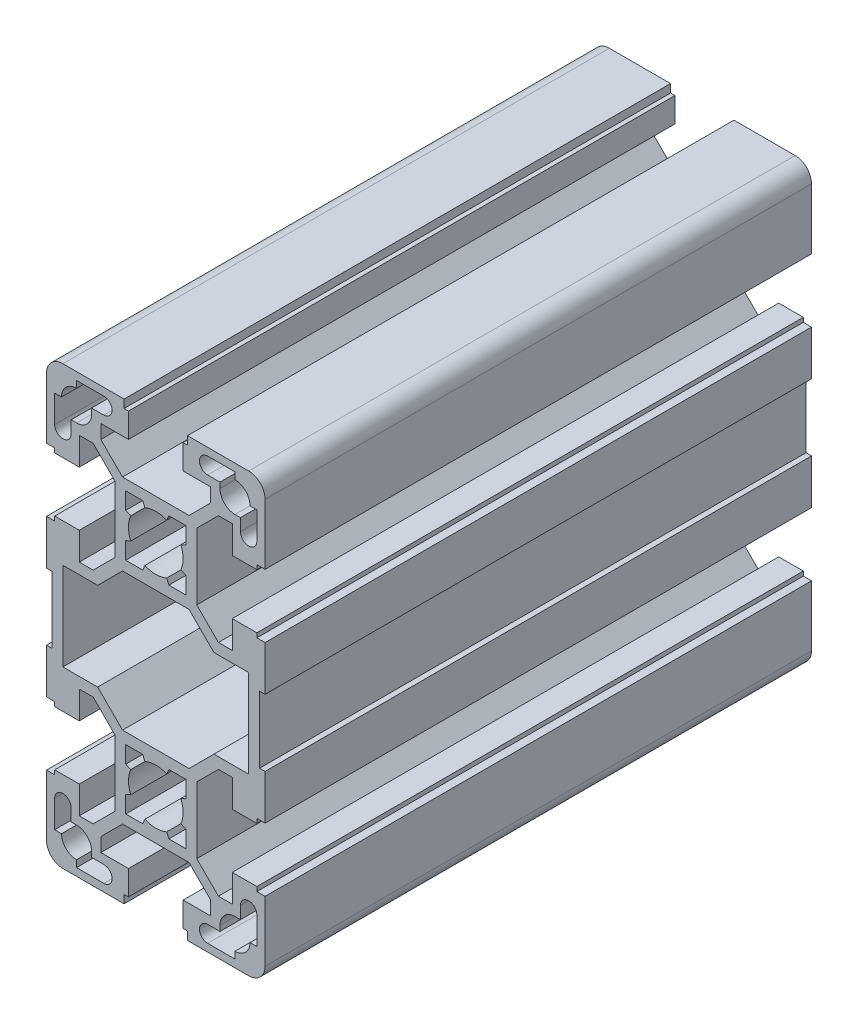
from build123d import *

# Parameters (mm, degrees)
EXTRUDE1_DEPTH = 100


with BuildPart() as part:
    # Sketch1 → Extrude1 (new body)
    with BuildSketch(Plane.XY):
        with BuildLine():
            Line((19, -6.108412677), (20, -6.108412677))
            Line((20, -6.108412677), (20, -14.308412677))
            Line((20, -14.308412677), (18.5, -14.308412677))
            Line((18.5, -14.308412677), (18.5, -15.108412677))
            Line((18.5, -15.108412677), (14, -15.108412677))
            Line((14, -15.108412677), (14, -10.058412677))
            Line((14, -10.058412677), (11.464213562, -10.058412677))
            Line((11.464213562, -10.058412677), (7.5, -14.02262624))
            Line((7.5, -14.02262624), (7.5, -26.194199115))
            Line((7.5, -26.194199115), (11.464213562, -30.158412677))
            Line((11.464213562, -30.158412677), (14, -30.158412677))
            Line((14, -30.158412677), (14, -25.108412677))
            Line((14, -25.108412677), (18.5, -25.108412677))
            Line((18.5, -25.108412677), (18.5, -25.908412677))
            Line((18.5, -25.908412677), (20, -25.908412677))
            Line((20, -25.908412677), (20, -37))
            ThreePointArc((20, -37), (19.121320344, -39.121320344), (17, -40))
            Line((17, -40), (5.8, -40))
            Line((5.8, -40), (5.8, -38.5))
            Line((5.8, -38.5), (5, -38.5))
            Line((5, -38.5), (5, -34))
            Line((5, -34), (10.05, -34))
            Line((10.05, -34), (10.05, -31.464213562))
            Line((10.05, -31.464213562), (6.085786438, -27.5))
            Line((6.085786438, -27.5), (-6.085786438, -27.5))
            Line((-6.085786438, -27.5), (-10.05, -31.464213562))
            Line((-10.05, -31.464213562), (-10.05, -34))
            Line((-10.05, -34), (-5, -34))
            Line((-5, -34), (-5, -38.5))
            Line((-5, -38.5), (-5.8, -38.5))
            Line((-5.8, -38.5), (-5.8, -40))
            Line((-5.8, -40), (-17, -40))
            ThreePointArc((-17, -40), (-19.121320344, -39.121320344), (-20, -37))
            Line((-20, -37), (-20, -25.908412677))
            Line((-20, -25.908412677), (-18.5, -25.908412677))
            Line((-18.5, -25.908412677), (-18.5, -25.108412677))
            Line((-18.5, -25.108412677), (-14, -25.108412677))
            Line((-14, -25.108412677), (-14, -30.158412677))
            Line((-14, -30.158412677), (-11.464213562, -30.158412677))
            Line((-11.464213562, -30.158412677), (-7.5, -26.194199115))
            Line((-7.5, -26.194199115), (-7.5, -14.02262624))
            Line((-7.5, -14.02262624), (-11.464213562, -10.058412677))
            Line((-11.464213562, -10.058412677), (-14, -10.058412677))
            Line((-14, -10.058412677), (-14, -15.108412677))
            Line((-14, -15.108412677), (-18.5, -15.108412677))
            Line((-18.5, -15.108412677), (-18.5, -14.308412677))
            Line((-18.5, -14.308412677), (-20, -14.308412677))
            Line((-20, -14.308412677), (-20, -6.108412677))
            Line((-20, -6.108412677), (-19, -6.108412677))
            Line((-19, -6.108412677), (-19, 6.108412677))
            Line((-19, 6.108412677), (-20, 6.108412677))
            Line((-20, 6.108412677), (-20, 14.308412677))
            Line((-20, 14.308412677), (-18.5, 14.308412677))
            Line((-18.5, 14.308412677), (-18.5, 15.108412677))
            Line((-18.5, 15.108412677), (-14, 15.108412677))
            Line((-14, 15.108412677), (-14, 10.058412677))
            Line((-14, 10.058412677), (-11.464213562, 10.058412677))
            Line((-11.464213562, 10.058412677), (-7.5, 14.02262624))
            Line((-7.5, 14.02262624), (-7.5, 26.194199115))
            Line((-7.5, 26.194199115), (-11.464213562, 30.158412677))
            Line((-11.464213562, 30.158412677), (-14, 30.158412677))
            Line((-14, 30.158412677), (-14, 25.108412677))
            Line((-14, 25.108412677), (-18.5, 25.108412677))
            Line((-18.5, 25.108412677), (-18.5, 25.908412677))
            Line((-18.5, 25.908412677), (-20, 25.908412677))
            Line((-20, 25.908412677), (-20, 37))
            ThreePointArc((-20, 37), (-19.121320344, 39.121320344), (-17, 40))
            Line((-17, 40), (-5.8, 40))
            Line((-5.8, 40), (-5.8, 38.5))
            Line((-5.8, 38.5), (-5, 38.5))
            Line((-5, 38.5), (-5, 34))
            Line((-5, 34), (-10.05, 34))
            Line((-10.05, 34), (-10.05, 31.464213562))
            Line((-10.05, 31.464213562), (-6.085786438, 27.5))
            Line((-6.085786438, 27.5), (6.085786438, 27.5))
            Line((6.085786438, 27.5), (10.05, 31.464213562))
            Line((10.05, 31.464213562), (10.05, 34))
            Line((10.05, 34), (5, 34))
            Line((5, 34), (5, 38.5))
            Line((5, 38.5), (5.8, 38.5))
            Line((5.8, 38.5), (5.8, 40))
            Line((5.8, 40), (17, 40))
            ThreePointArc((17, 40), (19.121320344, 39.121320344), (20, 37))
            Line((20, 37), (20, 25.908412677))
            Line((20, 25.908412677), (18.5, 25.908412677))
            Line((18.5, 25.908412677), (18.5, 25.108412677))
            Line((18.5, 25.108412677), (14, 25.108412677))
            Line((14, 25.108412677), (14, 30.158412677))
            Line((14, 30.158412677), (11.464213562, 30.158412677))
            Line((11.464213562, 30.158412677), (7.5, 26.194199115))
            Line((7.5, 26.194199115), (7.5, 14.02262624))
            Line((7.5, 14.02262624), (11.464213562, 10.058412677))
            Line((11.464213562, 10.058412677), (14, 10.058412677))
            Line((14, 10.058412677), (14, 15.108412677))
            Line((14, 15.108412677), (18.5, 15.108412677))
            Line((18.5, 15.108412677), (18.5, 14.308412677))
            Line((18.5, 14.308412677), (20, 14.308412677))
            Line((20, 14.308412677), (20, 6.108412677))
            Line((20, 6.108412677), (19, 6.108412677))
            Line((19, 6.108412677), (19, -6.108412677))
        make_face()
        Polygon((10.635786438, -8.058412677), (17, -8.058412677), (17, 8.058412677), (10.635786438, 8.058412677), (6.085786438, 12.608412677), (-6.085786438, 12.608412677), (-10.635786438, 8.058412677), (-17, 8.058412677), (-17, -8.058412677), (-10.635786438, -8.058412677), (-6.085786438, -12.608412677), (6.085786438, -12.608412677), align=None, mode=Mode.SUBTRACT)
        with BuildLine():
            Line((-18.5, -34.608412677), (-18.5, -29.608412677))
            ThreePointArc((-18.5, -29.608412677), (-17, -28.108412677), (-15.5, -29.608412677))
            Line((-15.5, -29.608412677), (-15.5, -31.858412677))
            Line((-15.5, -31.858412677), (-14.5, -31.858412677))
            ThreePointArc((-14.5, -31.858412677), (-12.555456352, -32.663869029), (-11.75, -34.608412677))
            Line((-11.75, -34.608412677), (-11.75, -35.608412677))
            Line((-11.75, -35.608412677), (-9.5, -35.608412677))
            ThreePointArc((-9.5, -35.608412677), (-8, -37.108412677), (-9.5, -38.608412677))
            Line((-9.5, -38.608412677), (-14.5, -38.608412677))
            Line((-14.5, -38.608412677), (-14.5, -37.358412677))
            ThreePointArc((-14.5, -37.358412677), (-16.444543648, -36.552956325), (-17.25, -34.608412677))
            Line((-17.25, -34.608412677), (-18.5, -34.608412677))
        make_face(mode=Mode.SUBTRACT)
        with BuildLine():
            Line((5.5, -14.608412677), (2.397915762, -14.608412677))
            Line((2.397915762, -14.608412677), (1.998263135, -15.525079344))
            ThreePointArc((1.998263135, -15.525079344), (0, -15.108412677), (-1.998263135, -15.525079344))
            Line((-1.998263135, -15.525079344), (-2.397915762, -14.608412677))
            Line((-2.397915762, -14.608412677), (-5.5, -14.608412677))
            Line((-5.5, -14.608412677), (-5.5, -17.710496916))
            Line((-5.5, -17.710496916), (-4.583333333, -18.110149542))
            ThreePointArc((-4.583333333, -18.110149542), (-5, -20.108412677), (-4.583333333, -22.106675812))
            Line((-4.583333333, -22.106675812), (-5.5, -22.506328439))
            Line((-5.5, -22.506328439), (-5.5, -25.608412677))
            Line((-5.5, -25.608412677), (-2.397915762, -25.608412677))
            Line((-2.397915762, -25.608412677), (-1.998263135, -24.691746011))
            ThreePointArc((-1.998263135, -24.691746011), (0, -25.108412677), (1.998263135, -24.691746011))
            Line((1.998263135, -24.691746011), (2.397915762, -25.608412677))
            Line((2.397915762, -25.608412677), (5.5, -25.608412677))
            Line((5.5, -25.608412677), (5.5, -22.506328439))
            Line((5.5, -22.506328439), (4.583333333, -22.106675812))
            ThreePointArc((4.583333333, -22.106675812), (5, -20.108412677), (4.583333333, -18.110149542))
            Line((4.583333333, -18.110149542), (5.5, -17.710496916))
            Line((5.5, -17.710496916), (5.5, -14.608412677))
        make_face(mode=Mode.SUBTRACT)
        with BuildLine():
            Line((15.5, -31.858412677), (14.5, -31.858412677))
            ThreePointArc((14.5, -31.858412677), (12.555456352, -32.663869029), (11.75, -34.608412677))
            Line((11.75, -34.608412677), (11.75, -35.608412677))
            Line((11.75, -35.608412677), (9.5, -35.608412677))
            ThreePointArc((9.5, -35.608412677), (8, -37.108412677), (9.5, -38.608412677))
            Line((9.5, -38.608412677), (14.5, -38.608412677))
            Line((14.5, -38.608412677), (14.5, -37.358412677))
            ThreePointArc((14.5, -37.358412677), (16.444543648, -36.552956325), (17.25, -34.608412677))
            Line((17.25, -34.608412677), (18.5, -34.608412677))
            Line((18.5, -34.608412677), (18.5, -29.608412677))
            ThreePointArc((18.5, -29.608412677), (17, -28.108412677), (15.5, -29.608412677))
            Line((15.5, -29.608412677), (15.5, -31.858412677))
        make_face(mode=Mode.SUBTRACT)
        with BuildLine():
            Line((18.5, 34.608412677), (18.5, 29.608412677))
            ThreePointArc((18.5, 29.608412677), (17, 28.108412677), (15.5, 29.608412677))
            Line((15.5, 29.608412677), (15.5, 31.858412677))
            Line((15.5, 31.858412677), (14.5, 31.858412677))
            ThreePointArc((14.5, 31.858412677), (12.555456352, 32.663869029), (11.75, 34.608412677))
            Line((11.75, 34.608412677), (11.75, 35.608412677))
            Line((11.75, 35.608412677), (9.5, 35.608412677))
            ThreePointArc((9.5, 35.608412677), (8, 37.108412677), (9.5, 38.608412677))
            Line((9.5, 38.608412677), (14.5, 38.608412677))
            Line((14.5, 38.608412677), (14.5, 37.358412677))
            ThreePointArc((14.5, 37.358412677), (16.444543648, 36.552956325), (17.25, 34.608412677))
            Line((17.25, 34.608412677), (18.5, 34.608412677))
        make_face(mode=Mode.SUBTRACT)
        with BuildLine():
            Line((-5.5, 14.608412677), (-2.397915762, 14.608412677))
            Line((-2.397915762, 14.608412677), (-1.998263135, 15.525079344))
            ThreePointArc((-1.998263135, 15.525079344), (0, 15.108412677), (1.998263135, 15.525079344))
            Line((1.998263135, 15.525079344), (2.397915762, 14.608412677))
            Line((2.397915762, 14.608412677), (5.5, 14.608412677))
            Line((5.5, 14.608412677), (5.5, 17.710496916))
            Line((5.5, 17.710496916), (4.583333333, 18.110149542))
            ThreePointArc((4.583333333, 18.110149542), (5, 20.108412677), (4.583333333, 22.106675812))
            Line((4.583333333, 22.106675812), (5.5, 22.506328439))
            Line((5.5, 22.506328439), (5.5, 25.608412677))
            Line((5.5, 25.608412677), (2.397915762, 25.608412677))
            Line((2.397915762, 25.608412677), (1.998263135, 24.691746011))
            ThreePointArc((1.998263135, 24.691746011), (0, 25.108412677), (-1.998263135, 24.691746011))
            Line((-1.998263135, 24.691746011), (-2.397915762, 25.608412677))
            Line((-2.397915762, 25.608412677), (-5.5, 25.608412677))
            Line((-5.5, 25.608412677), (-5.5, 22.506328439))
            Line((-5.5, 22.506328439), (-4.583333333, 22.106675812))
            ThreePointArc((-4.583333333, 22.106675812), (-5, 20.108412677), (-4.583333333, 18.110149542))
            Line((-4.583333333, 18.110149542), (-5.5, 17.710496916))
            Line((-5.5, 17.710496916), (-5.5, 14.608412677))
        make_face(mode=Mode.SUBTRACT)
        with BuildLine():
            Line((-15.5, 31.858412677), (-14.5, 31.858412677))
            ThreePointArc((-14.5, 31.858412677), (-12.555456352, 32.663869029), (-11.75, 34.608412677))
            Line((-11.75, 34.608412677), (-11.75, 35.608412677))
            Line((-11.75, 35.608412677), (-9.5, 35.608412677))
            ThreePointArc((-9.5, 35.608412677), (-8, 37.108412677), (-9.5, 38.608412677))
            Line((-9.5, 38.608412677), (-14.5, 38.608412677))
            Line((-14.5, 38.608412677), (-14.5, 37.358412677))
            ThreePointArc((-14.5, 37.358412677), (-16.444543648, 36.552956325), (-17.25, 34.608412677))
            Line((-17.25, 34.608412677), (-18.5, 34.608412677))
            Line((-18.5, 34.608412677), (-18.5, 29.608412677))
            ThreePointArc((-18.5, 29.608412677), (-17, 28.108412677), (-15.5, 29.608412677))
            Line((-15.5, 29.608412677), (-15.5, 31.858412677))
        make_face(mode=Mode.SUBTRACT)
    extrude(amount=-EXTRUDE1_DEPTH)


solid = part.part
